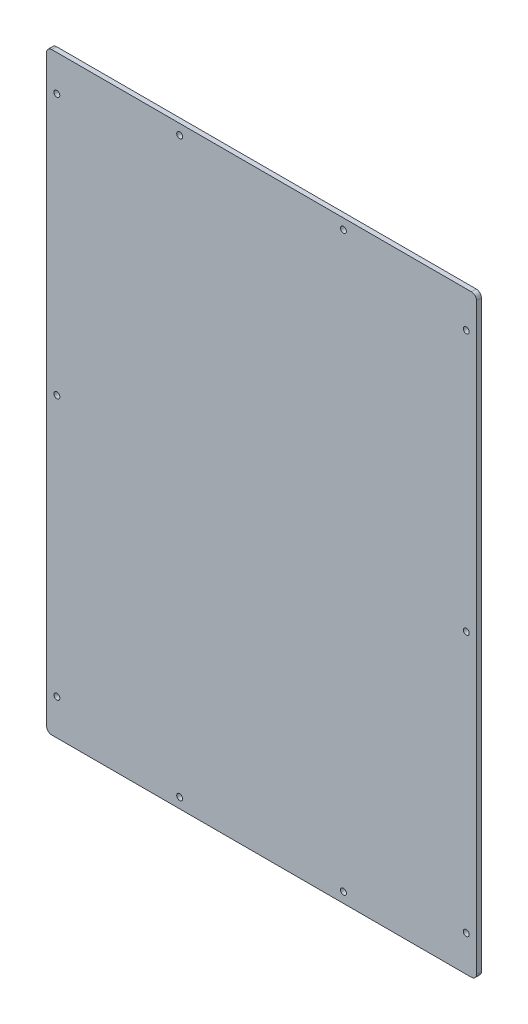
from build123d import *

# Parameters (mm, degrees)
SKETCH1_W            = 420
SKETCH1_H            = 580
BOSS_EXTRUDE1_DEPTH  = 4.7625
M5_CLEARANCE_HOLE1_D = 5.8
FILLET1_R            = 5


with BuildPart() as part:
    # Sketch1 → Boss-Extrude1 (new body)
    with BuildSketch(Plane.XY):
        Rectangle(SKETCH1_W, SKETCH1_H)
    extrude(amount=BOSS_EXTRUDE1_DEPTH)

    # M5 Clearance Hole1 (through all)
    with Locations(Plane.XY.offset(4.7625)):
        with Locations((-200, 255), (-200, 0), (-200, -255), (200, 255), (200, 0), (200, -255), (-80, 280), (80, 280), (80, -280), (-80, -280)):
            Hole(M5_CLEARANCE_HOLE1_D / 2)

    # Fillet1
    fillet1_edges = [part.edges().sort_by_distance(p)[0] for p in [
        (-210, 290, 2.38125),
        (210, 290, 2.38125),
        (210, -290, 2.38125),
        (-210, -290, 2.38125),
    ]]
    fillet(fillet1_edges, radius=FILLET1_R)


solid = part.part
